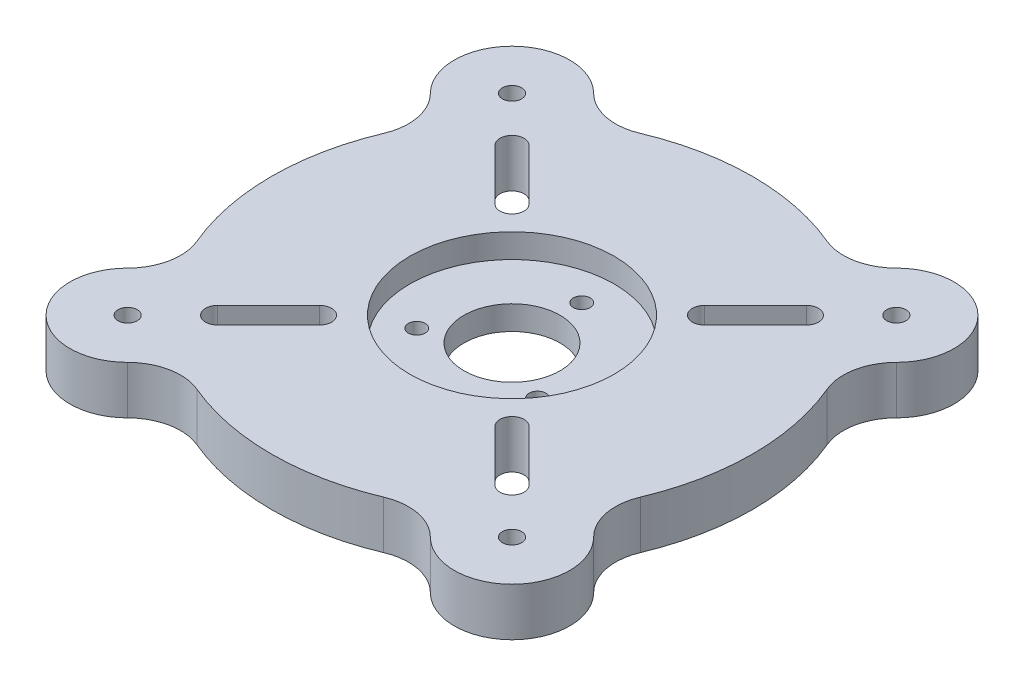
from build123d import *

# Parameters (mm, degrees)
SZKIC1_R                    = 50
SZKIC1_R_2                  = 2
DODANIE_WYCI_GNI_CIE1_DEPTH = 10
SZKIC3_R                    = 21.25
WYTNIJ_WYCI_GNI_CIE4_DEPTH  = 5
SZKIC3_5_R                  = 1.75
SZKIC3_5_R_2                = 10
WYTNIJ_WYCI_GNI_CIE5_DEPTH  = 11


with BuildPart() as part:
    # Szkic1 → Dodanie-wyci_gni_cie1 (new body)
    with BuildSketch(Plane(origin=(0, 0, 0), x_dir=(1, 0, 0), z_dir=(0, 1, 0))):
        Circle(SZKIC1_R)
        with BuildLine():
            ThreePointArc((-28.838834765, 32.374368671), (-32.374368671, 32.374368671), (-32.374368671, 28.838834765))
            Line((-32.374368671, 28.838834765), (-21.767766953, 18.232233047))
            ThreePointArc((-21.767766953, 18.232233047), (-18.232233047, 18.232233047), (-18.232233047, 21.767766953))
            Line((-18.232233047, 21.767766953), (-28.838834765, 32.374368671))
        make_face(mode=Mode.SUBTRACT)
        with BuildLine():
            ThreePointArc((-32.374368671, -28.838834765), (-32.374368671, -32.374368671), (-28.838834765, -32.374368671))
            Line((-28.838834765, -32.374368671), (-18.232233047, -21.767766953))
            ThreePointArc((-18.232233047, -21.767766953), (-18.232233047, -18.232233047), (-21.767766953, -18.232233047))
            Line((-21.767766953, -18.232233047), (-32.374368671, -28.838834765))
        make_face(mode=Mode.SUBTRACT)
        with BuildLine():
            ThreePointArc((28.838834765, -32.374368671), (32.374368671, -32.374368671), (32.374368671, -28.838834765))
            Line((32.374368671, -28.838834765), (21.767766953, -18.232233047))
            ThreePointArc((21.767766953, -18.232233047), (18.232233047, -18.232233047), (18.232233047, -21.767766953))
            Line((18.232233047, -21.767766953), (28.838834765, -32.374368671))
        make_face(mode=Mode.SUBTRACT)
        with BuildLine():
            ThreePointArc((32.374368671, 28.838834765), (32.374368671, 32.374368671), (28.838834765, 32.374368671))
            Line((28.838834765, 32.374368671), (18.232233047, 21.767766953))
            ThreePointArc((18.232233047, 21.767766953), (18.232233047, 18.232233047), (21.767766953, 18.232233047))
            Line((21.767766953, 18.232233047), (32.374368671, 28.838834765))
        make_face(mode=Mode.SUBTRACT)
        with BuildLine():
            ThreePointArc((-31.466251763, -48.436814511), (-25.799706685, -45.41900176), (-19.413503243, -46.077281732))
            ThreePointArc((-19.413503243, -46.077281732), (-35.355339059, -35.355339059), (-46.077281732, -19.413503243))
            ThreePointArc((-46.077281732, -19.413503243), (-45.41900176, -25.799706685), (-48.436814511, -31.466251763))
            ThreePointArc((-48.436814511, -31.466251763), (-48.436814511, -48.436814511), (-31.466251763, -48.436814511))
        make_face()
        with Locations((-39.951533137, -39.951533137)):
            Circle(SZKIC1_R_2, mode=Mode.SUBTRACT)
        with BuildLine():
            ThreePointArc((-46.077281732, 19.413503243), (-35.355339059, 35.355339059), (-19.413503243, 46.077281732))
            ThreePointArc((-19.413503243, 46.077281732), (-25.799706685, 45.41900176), (-31.466251763, 48.436814511))
            ThreePointArc((-31.466251763, 48.436814511), (-48.436814511, 48.436814511), (-48.436814511, 31.466251763))
            ThreePointArc((-48.436814511, 31.466251763), (-45.41900176, 25.799706685), (-46.077281732, 19.413503243))
        make_face()
        with Locations((-39.951533137, 39.951533137)):
            Circle(SZKIC1_R_2, mode=Mode.SUBTRACT)
        with BuildLine():
            ThreePointArc((19.413503243, 46.077281732), (35.355339059, 35.355339059), (46.077281732, 19.413503243))
            ThreePointArc((46.077281732, 19.413503243), (45.41900176, 25.799706685), (48.436814511, 31.466251763))
            ThreePointArc((48.436814511, 31.466251763), (48.436814511, 48.436814511), (31.466251763, 48.436814511))
            ThreePointArc((31.466251763, 48.436814511), (25.799706685, 45.41900176), (19.413503243, 46.077281732))
        make_face()
        with Locations((39.951533137, 39.951533137)):
            Circle(SZKIC1_R_2, mode=Mode.SUBTRACT)
        with BuildLine():
            ThreePointArc((48.436814511, -31.466251763), (45.41900176, -25.799706685), (46.077281732, -19.413503243))
            ThreePointArc((46.077281732, -19.413503243), (35.355339059, -35.355339059), (19.413503243, -46.077281732))
            ThreePointArc((19.413503243, -46.077281732), (25.799706685, -45.41900176), (31.466251763, -48.436814511))
            ThreePointArc((31.466251763, -48.436814511), (48.436814511, -48.436814511), (48.436814511, -31.466251763))
        make_face()
        with Locations((39.951533137, -39.951533137)):
            Circle(SZKIC1_R_2, mode=Mode.SUBTRACT)
    extrude(amount=DODANIE_WYCI_GNI_CIE1_DEPTH)

    # Szkic3 → Wytnij-wyci_gni_cie4 (cut)
    with BuildSketch(Plane(origin=(0, 10, 0), x_dir=(1, 0, 0), z_dir=(0, 1, 0))):
        Circle(SZKIC3_R)
    extrude(amount=-WYTNIJ_WYCI_GNI_CIE4_DEPTH, mode=Mode.SUBTRACT)

    # Szkic3_5 → Wytnij-wyci_gni_cie5 (cut, through all)
    with BuildSketch(Plane(origin=(0, 10, 0), x_dir=(1, 0, 0), z_dir=(0, 1, 0))):
        with Locations((0, 14.5)):
            Circle(SZKIC3_5_R)
        with Locations((12.558868355, -7.249133975)):
            Circle(SZKIC3_5_R)
        with Locations((-12.555868355, -7.250866025)):
            Circle(SZKIC3_5_R)
        Circle(SZKIC3_5_R_2)
    extrude(amount=-WYTNIJ_WYCI_GNI_CIE5_DEPTH, mode=Mode.SUBTRACT)


solid = part.part
